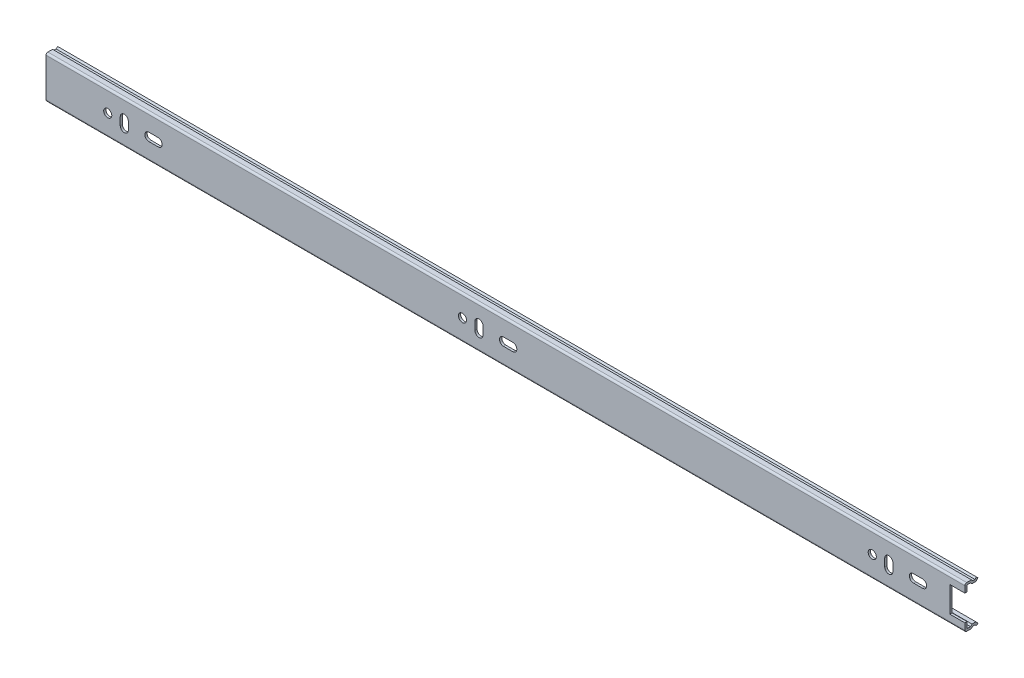
from build123d import *

# Parameters (mm, degrees)
EXTRUDE_3_DEPTH     = 500
SKETCH_2_R          = 2.2
SKETCH_2_W          = 8.2
SKETCH_2_H          = 14
CUT_EXTRUDE_1_DEPTH = 8.148528137


with BuildPart() as part:
    # Эскиз1 → Вытянуть-Тонкостенный3 (new body)
    with BuildSketch(Plane(origin=(0, 0, 0), x_dir=(0, 0, -1), z_dir=(1, 0, 0))):
        with BuildLine():
            Line((6.3, 11.5), (5.501920783, 10.701920783))
            Line((5.501920783, 10.701920783), (4.371381229, 10.701920783))
            Line((4.371381229, 10.701920783), (3.573302011, 11.5))
            Line((3.573302011, 11.5), (1, 11.5))
            ThreePointArc((1, 11.5), (0.292893219, 11.207106781), (0, 10.5))
            Line((0, 10.5), (0, -10.5))
            ThreePointArc((0, -10.5), (0.292893219, -11.207106781), (1, -11.5))
            Line((1, -11.5), (3.573302011, -11.5))
            Line((3.573302011, -11.5), (4.371381229, -10.701920783))
            Line((4.371381229, -10.701920783), (5.501920783, -10.701920783))
            Line((5.501920783, -10.701920783), (6.3, -11.5))
            Line((6.3, -11.5), (7.148528137, -10.651471863))
            Line((7.148528137, -10.651471863), (5.998977057, -9.501920783))
            Line((5.998977057, -9.501920783), (3.874324954, -9.501920783))
            Line((3.874324954, -9.501920783), (3.076245737, -10.3))
            Line((3.076245737, -10.3), (1.2, -10.3))
            Line((1.2, -10.3), (1.2, 10.3))
            Line((1.2, 10.3), (3.076245737, 10.3))
            Line((3.076245737, 10.3), (3.874324954, 9.501920783))
            Line((3.874324954, 9.501920783), (5.998977057, 9.501920783))
            Line((5.998977057, 9.501920783), (7.148528137, 10.651471863))
            Line((7.148528137, 10.651471863), (6.3, 11.5))
        make_face()
    extrude(amount=EXTRUDE_3_DEPTH)

    # Эскиз2 → Вырез-Вытянуть1 (cut, through all)
    with BuildSketch(Plane.XY):
        with Locations((449.6, 0)):
            Circle(SKETCH_2_R)
        with Locations((226.6, 0)):
            Circle(SKETCH_2_R)
        with Locations((33.6, 0)):
            Circle(SKETCH_2_R)
        with Locations((495.9, 0)):
            Rectangle(SKETCH_2_W, SKETCH_2_H)
        with BuildLine():
            Line((472, 2.2), (477, 2.2))
            ThreePointArc((477, 2.2), (479.2, 0), (477, -2.2))
            Line((477, -2.2), (472, -2.2))
            ThreePointArc((472, -2.2), (469.8, 0), (472, 2.2))
        make_face()
        with BuildLine():
            Line((456.4, 1.779598361), (456.4, -2.5))
            ThreePointArc((456.4, -2.5), (458.6, -4.7), (460.8, -2.5))
            Line((460.8, -2.5), (460.8, 1.779598361))
            ThreePointArc((460.8, 1.779598361), (458.6, 3.979598361), (456.4, 1.779598361))
        make_face()
        with BuildLine():
            Line((233.4, 1.779598361), (233.4, -2.5))
            ThreePointArc((233.4, -2.5), (235.6, -4.7), (237.8, -2.5))
            Line((237.8, -2.5), (237.8, 1.779598361))
            ThreePointArc((237.8, 1.779598361), (235.6, 3.979598361), (233.4, 1.779598361))
        make_face()
        with BuildLine():
            Line((249, -2.2), (254, -2.2))
            ThreePointArc((254, -2.2), (256.2, 0), (254, 2.2))
            Line((254, 2.2), (249, 2.2))
            ThreePointArc((249, 2.2), (246.8, 0), (249, -2.2))
        make_face()
        with BuildLine():
            Line((44.8, -2.5), (44.8, 1.779598361))
            ThreePointArc((44.8, 1.779598361), (42.6, 3.979598361), (40.4, 1.779598361))
            Line((40.4, 1.779598361), (40.4, -2.5))
            ThreePointArc((40.4, -2.5), (42.6, -4.7), (44.8, -2.5))
        make_face()
        with BuildLine():
            Line((56, 2.2), (61, 2.2))
            ThreePointArc((61, 2.2), (63.2, 0), (61, -2.2))
            Line((61, -2.2), (56, -2.2))
            ThreePointArc((56, -2.2), (53.8, 0), (56, 2.2))
        make_face()
    extrude(amount=-CUT_EXTRUDE_1_DEPTH, mode=Mode.SUBTRACT)


solid = part.part
